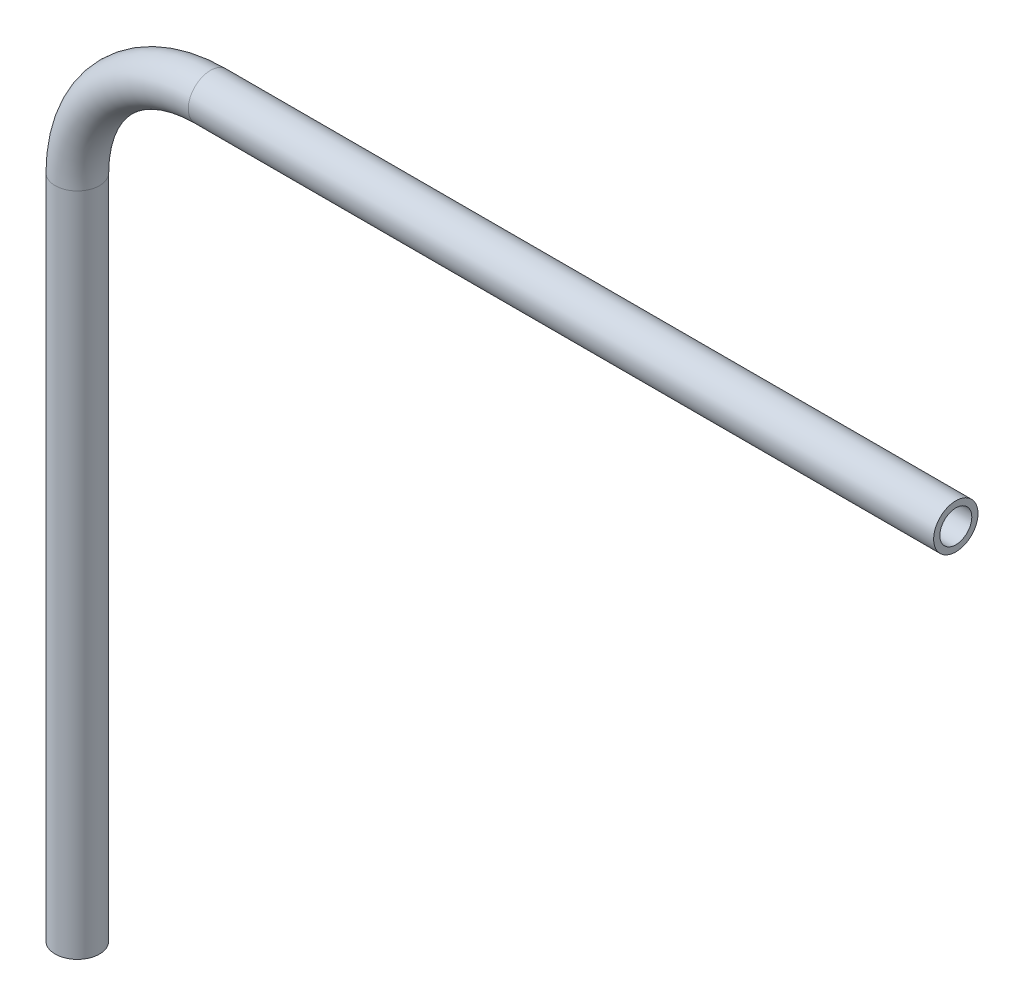
from build123d import *

# Parameters (mm, degrees)
SKETCH2_R   = 3.175
SKETCH2_R_2 = 2.286


with BuildPart() as part:
    # Sweep1: sweep along a path in Sketch1
    with BuildLine(Plane.XY) as sweep1_path:
        Line((0, -96.772317881), (0, -1.522317881))
        ThreePointArc((0, -1.522317881), (5.579615818, 11.948066301), (19.05, 17.527682119))
        Line((19.05, 17.527682119), (125.73, 17.527682119))
    # Sketch2 → Sweep1 (sweep)
    with BuildSketch(Plane(origin=(125.73, 17.527682119, 0), x_dir=(0, 0, -1), z_dir=(1, 0, 0))):
        Circle(SKETCH2_R)
        Circle(SKETCH2_R_2, mode=Mode.SUBTRACT)
    sweep(path=sweep1_path.line)


solid = part.part
